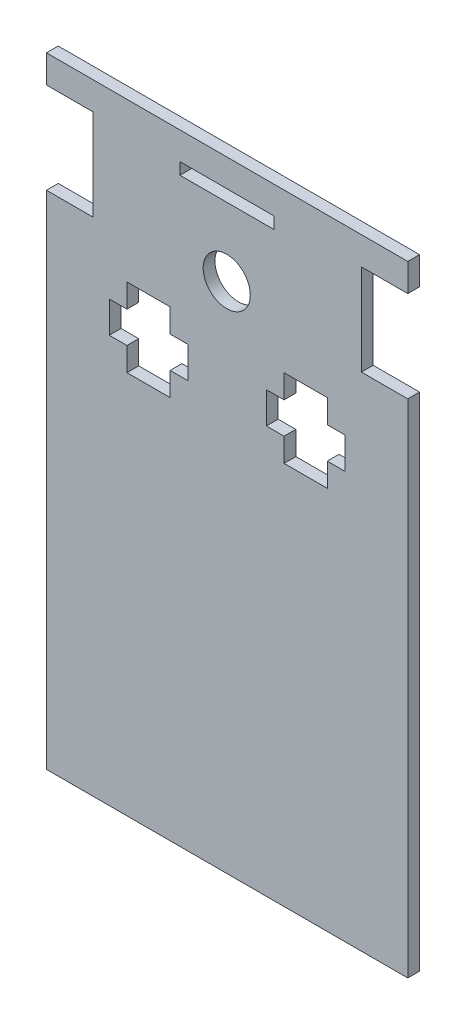
from build123d import *

# Parameters (mm, degrees)
MODEL_R                 = 6
MODEL_W                 = 24
MODEL_H                 = 3
SALIENTE_EXTRUIR1_DEPTH = 3


with BuildPart() as part:
    # Model → Saliente-Extruir1 (new body)
    with BuildSketch(Plane.XY):
        Polygon((54, 89), (54, 81.9), (65.8, 81.9), (65.8, 58.7), (54, 58.7), (54, -69), (146, -69), (146, 58.7), (134.2, 58.7), (134.2, 81.9), (146, 81.9), (146, 89), align=None)
        with Locations((99.899304233, 61.529562992)):
            Circle(MODEL_R, mode=Mode.SUBTRACT)
        with Locations((100, 80.5)):
            Rectangle(MODEL_W, MODEL_H, mode=Mode.SUBTRACT)
        Polygon((85.5, 28.721585816), (85.5, 34.721585816), (90, 34.721585816), (90, 42.721585816), (85.5, 42.721585816), (85.5, 48.721585816), (74.5, 48.721585816), (74.5, 42.721585816), (70, 42.721585816), (70, 34.721585816), (74.5, 34.721585816), (74.5, 28.721585816), align=None, mode=Mode.SUBTRACT)
        Polygon((125.5, 28.721575199), (125.5, 34.721575199), (130, 34.721575199), (130, 42.721575199), (125.5, 42.721575199), (125.5, 48.721575199), (114.5, 48.721575199), (114.5, 42.721575199), (110, 42.721575199), (110, 34.721575199), (114.5, 34.721575199), (114.5, 28.721575199), align=None, mode=Mode.SUBTRACT)
    extrude(amount=SALIENTE_EXTRUIR1_DEPTH)


solid = part.part
